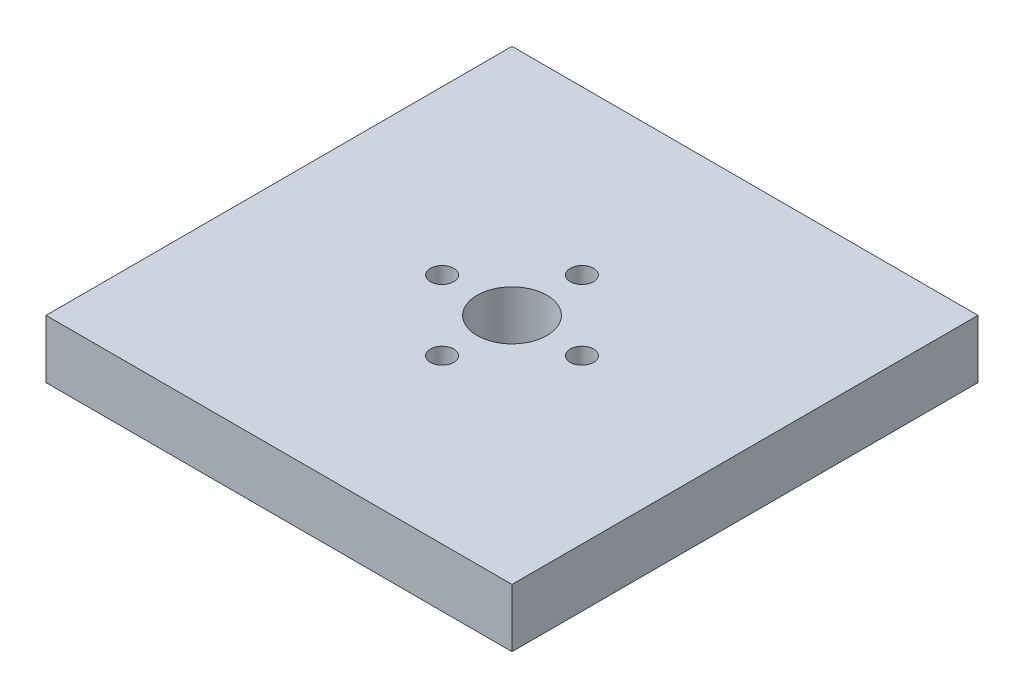
from build123d import *

# Parameters (mm, degrees)
SKETCH1_W               = 40
SKETCH1_H               = 40
BOSS_EXTRUDE1_DEPTH     = 5
CUT_EXTRUDE4_DEPTH      = 15
CUT_EXTRUDE4_DEPTH_BACK = 15
SKETCH8_R               = 3
SKETCH8_R_2             = 1


with BuildPart() as part:
    # Sketch1 → Boss-Extrude1 (new body)
    with BuildSketch(Plane(origin=(0, 0, 0), x_dir=(1, 0, 0), z_dir=(0, 1, 0))):
        with Locations((20, 20)):
            Rectangle(SKETCH1_W, SKETCH1_H)
    extrude(amount=BOSS_EXTRUDE1_DEPTH)

    # Sketch8 → Cut-Extrude4 (cut, two sides: drawn at the far end of the back side and taken through both)
    with BuildSketch(Plane(origin=(0, 5, 0), x_dir=(1, 0, 0), z_dir=(0, 1, 0)).offset(-CUT_EXTRUDE4_DEPTH_BACK)):
        with Locations((20, 20)):
            Circle(SKETCH8_R)
        with Locations((20, 14)):
            Circle(SKETCH8_R_2)
        with Locations((26, 20)):
            Circle(SKETCH8_R_2)
        with Locations((14, 20)):
            Circle(SKETCH8_R_2)
        with Locations((20, 26)):
            Circle(SKETCH8_R_2)
    extrude(amount=CUT_EXTRUDE4_DEPTH + CUT_EXTRUDE4_DEPTH_BACK, mode=Mode.SUBTRACT)


solid = part.part
